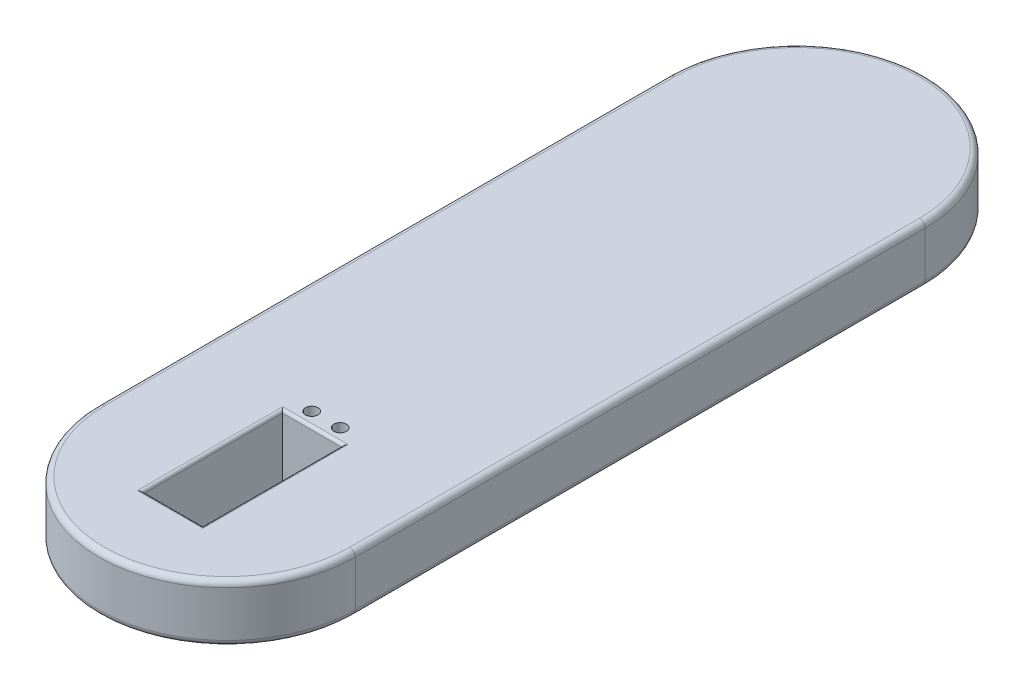
from build123d import *

# Parameters (mm, degrees)
SKETCH1_R           = 2.2
BOSS_EXTRUDE1_DEPTH = 20
FILLET1_R           = 2
SKETCH4_R           = 11
CUT_EXTRUDE2_DEPTH  = 6.35
SKETCH5_W           = 31
SKETCH5_H           = 52
BOSS_EXTRUDE2_DEPTH = 36
SKETCH7_W           = 21
SKETCH7_H           = 49
CUT_EXTRUDE4_DEPTH  = 26
FILLET2_R           = 1
SKETCH8_R           = 2.2
CUT_EXTRUDE5_DEPTH  = 37


with BuildPart() as part:
    # Sketch1 → Boss-Extrude1 (new body)
    with BuildSketch(Plane(origin=(0, 0, 0), x_dir=(1, 0, 0), z_dir=(0, 1, 0))):
        with BuildLine():
            Line((0, 0), (0, 200))
            ThreePointArc((0, 200), (-45, 245), (-90, 200))
            Line((-90, 200), (-90, 0))
            ThreePointArc((-90, 0), (-45, -45), (0, 0))
        make_face()
        with Locations((-50, 34.589613301)):
            Circle(SKETCH1_R, mode=Mode.SUBTRACT)
        with Locations((-40, 34.589613301)):
            Circle(SKETCH1_R, mode=Mode.SUBTRACT)
    extrude(amount=-BOSS_EXTRUDE1_DEPTH)

    # Fillet1
    fillet1_edges = [part.edges().sort_by_distance(p)[0] for p in [
        (-45, -20, -245),
        (-90, -20, -100),
        (-45, -20, 45),
        (-90, 0, -100),
        (-45, 0, -245),
        (0, 0, -100),
        (-45, 0, 45),
        (0, -20, -100),
    ]]
    fillet(fillet1_edges, radius=FILLET1_R)

    # Sketch4 → Cut-Extrude2 (cut)
    with BuildSketch(Plane.XZ.offset(20)):
        with Locations((-45.5, -200)):
            Circle(SKETCH4_R)
    extrude(amount=-CUT_EXTRUDE2_DEPTH, mode=Mode.SUBTRACT)

    # Sketch5 → Boss-Extrude2 (add)
    with BuildSketch(Plane(origin=(0, 0, 0), x_dir=(1, 0, 0), z_dir=(0, 1, 0))):
        with Locations((-45, 15)):
            Rectangle(SKETCH5_W, SKETCH5_H)
    extrude(amount=-BOSS_EXTRUDE2_DEPTH)

    # Sketch7 → Cut-Extrude4 (cut)
    with BuildSketch(Plane(origin=(0, 0, 0), x_dir=(1, 0, 0), z_dir=(0, 1, 0))):
        with Locations((-45, 5.5)):
            Rectangle(SKETCH7_W, SKETCH7_H)
    extrude(amount=-CUT_EXTRUDE4_DEPTH, mode=Mode.SUBTRACT)

    # Fillet2
    fillet2_edges = [part.edges().sort_by_distance(p)[0] for p in [
        (-45, 0, 19),
        (-34.5, 0, -5.5),
        (-45, 0, -30),
        (-55.5, 0, -5.5),
    ]]
    fillet(fillet2_edges, radius=FILLET2_R)

    # Sketch8 → Cut-Extrude5 (cut, through all)
    with BuildSketch(Plane(origin=(0, 0, 0), x_dir=(1, 0, 0), z_dir=(0, 1, 0))):
        with Locations((-50, 34.7)):
            Circle(SKETCH8_R)
        with Locations((-40, 34.7)):
            Circle(SKETCH8_R)
    extrude(amount=-CUT_EXTRUDE5_DEPTH, mode=Mode.SUBTRACT)


solid = part.part
